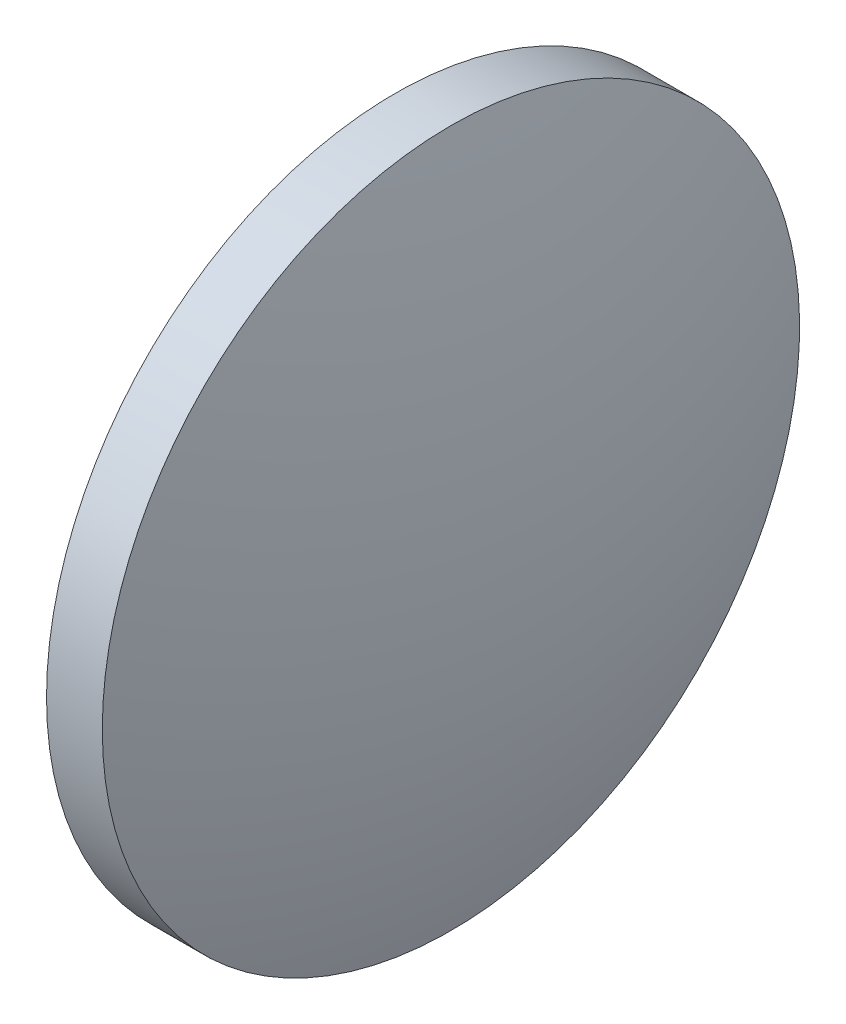
from build123d import *


with BuildPart() as part:
    # 草图1 → 旋转1 (revolve)
    with BuildSketch(Plane.XY):
        with BuildLine():
            Line((691.912571857, 125.554307898), (691.912571857, 138.054307898))
            Line((691.912571857, 138.054307898), (693.912571857, 138.054307898))
            ThreePointArc((693.912571857, 138.054307898), (695.364685957, 131.879132007), (695.852571857, 125.554307898))
            Line((695.852571857, 125.554307898), (691.912571857, 125.554307898))
        make_face()
    revolve(axis=Axis((689.883464279, 125.554307898, 0), (1, 0, 0)))


solid = part.part
